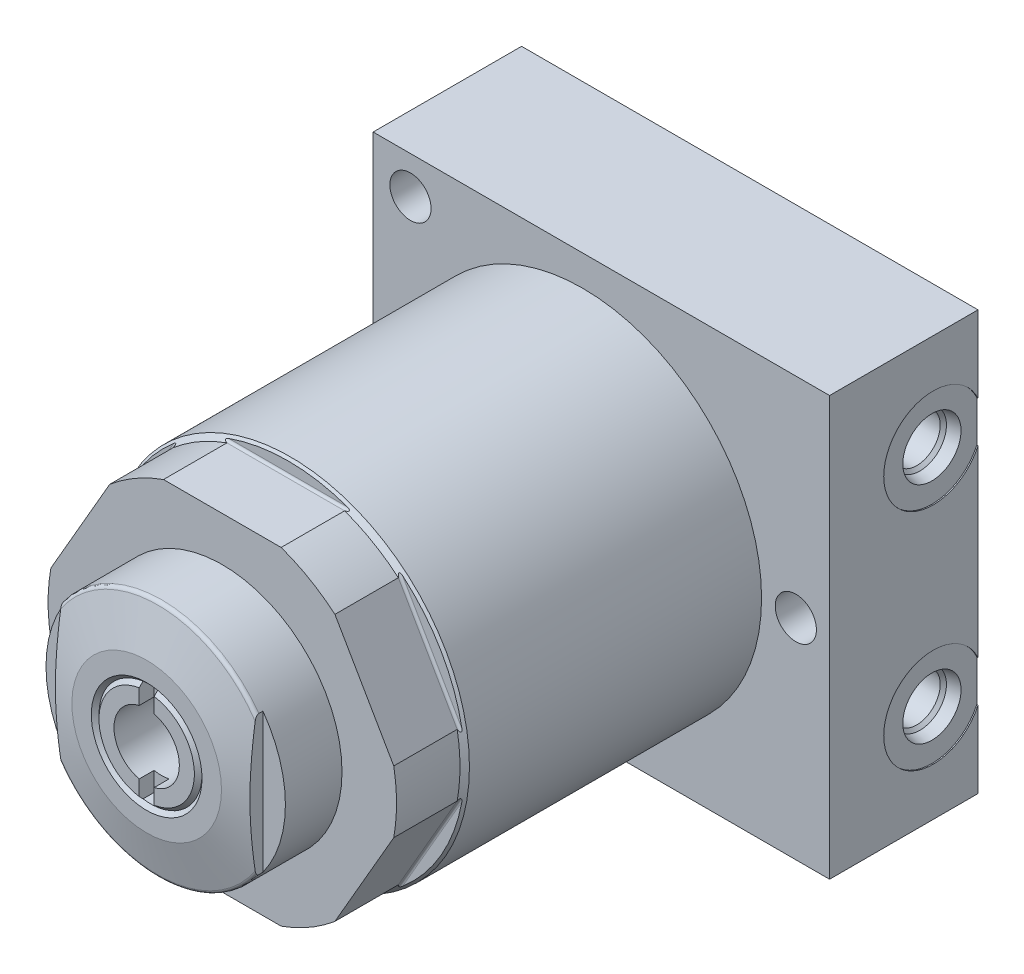
from build123d import *

# Parameters (mm, degrees)
SKETCH1_R           = 37.973
EXTRUDE1_DEPTH      = 96.8502
CUT_EXTRUDE1_DEPTH  = 45.5676
SKETCH13_W          = 16.0528
SKETCH13_H          = 25.4
S2D0011_W           = 6.9342
S2D0011_H           = 16.002
SKETCH16_W          = 96.8502
SKETCH16_H          = 31.496
EXTRUDE2_DEPTH      = 44.45
EXTRUDE2_DEPTH_BACK = 44.45
SKETCH17_R          = 10.4775
CUT_EXTRUDE9_DEPTH  = 0.254
SKETCH18_R          = 10.4775
CUT_EXTRUDE10_DEPTH = 0.254
HOLE1_D             = 8.7376
HOLE1_DEPTH         = 31.496
CIRPATTERN2_COUNT   = 6
CUT_EXTRUDE11_DEPTH = 4.0386
CUT_EXTRUDE12_DEPTH = 3.175


with BuildPart() as part:
    # Sketch1 → Extrude1 (new body)
    with BuildSketch(Plane.XY):
        Circle(SKETCH1_R)
    extrude(amount=EXTRUDE1_DEPTH)

    # Sketch2 → Cut-Extrude1 (cut, symmetric)
    with BuildSketch(Plane(origin=(0, 0, 0), x_dir=(0, 0, 1), z_dir=(1, 0, 0))):
        with BuildLine():
            Line((82.8802, 37.973), (82.8802, 35.306))
            ThreePointArc((82.8802, 35.306), (83.028989755, 34.946789755), (83.3882, 34.798))
            Line((83.3882, 34.798), (96.8502, 34.798))
            Line((96.8502, 34.798), (96.8502, 37.973))
            Line((96.8502, 37.973), (82.8802, 37.973))
        make_face()
    cut_extrude1 = extrude(amount=CUT_EXTRUDE1_DEPTH, both=True, mode=Mode.SUBTRACT)

    # Sketch10 → Cut-Revolve1 (revolve, cut)
    with BuildSketch(Plane(origin=(0, 0, 0), x_dir=(0, 0, -1), z_dir=(1, 0, 0)), mode=Mode.PRIVATE) as cut_revolve1_sk:
        Polygon((-96.8502, 36.9697), (-83.3882, 36.9697), (-82.3849, 37.973), (-96.8502, 37.973), align=None)
    revolve(cut_revolve1_sk.sketch.rotate(Axis((0, 0, 97.573465), (0, 0, -1)), 90), axis=Axis((0, 0, 97.573465), (0, 0, -1)), mode=Mode.SUBTRACT)  # turned: the seam where the file's is

    # Sketch13 → Revolve1 (revolve)
    with BuildSketch(Plane(origin=(0, 0, 0), x_dir=(0, 0, -1), z_dir=(1, 0, 0)), mode=Mode.PRIVATE) as revolve1_sk:
        with Locations((-104.8766, 12.7)):
            Rectangle(SKETCH13_W, SKETCH13_H)
    revolve(revolve1_sk.sketch.rotate(Axis((0, 0, 113.59896), (0, 0, -1)), 90), axis=Axis((0, 0, 113.59896), (0, 0, -1)))  # turned: the seam where the file's is

    # S2D0011 → Cut-Revolve4 (revolve, cut)
    with BuildSketch(Plane(origin=(-6.9342, 0, 112.8014), x_dir=(-1, 0, 0), z_dir=(0, 1, 0)), mode=Mode.PRIVATE) as cut_revolve4_sk:
        with Locations((-3.4671, -7.8994)):
            Rectangle(S2D0011_W, S2D0011_H)
    revolve(cut_revolve4_sk.sketch.rotate(Axis((0, 0, 71.846012298), (0, 0, 1)), 180), axis=Axis((0, 0, 71.846012298), (0, 0, 1)), mode=Mode.SUBTRACT)  # turned: the seam where the file's is

    # Sketch15 → Cut-Revolve5 (revolve, cut)
    with BuildSketch(Plane(origin=(0, 0, 0), x_dir=(0, 0, -1), z_dir=(1, 0, 0)), mode=Mode.PRIVATE) as cut_revolve5_sk:
        with BuildLine():
            Line((-112.903, 15.875), (-110.513124294, 24.797494276))
            ThreePointArc((-110.513124294, 24.797494276), (-110.222831614, 25.232014325), (-109.728, 25.4))
            Line((-109.728, 25.4), (-112.903, 25.4))
            Line((-112.903, 25.4), (-112.903, 15.875))
        make_face()
    revolve(cut_revolve5_sk.sketch.rotate(Axis((0, 0, 112.96015), (0, 0, -1)), 90), axis=Axis((0, 0, 112.96015), (0, 0, -1)), mode=Mode.SUBTRACT)  # turned: the seam where the file's is

    # Sketch16 → Extrude2 (add, two sides)
    with BuildSketch(Plane(origin=(0, 0, 0), x_dir=(-1, 0, 0), z_dir=(0, 1, 0))) as extrude2_sk:
        with Locations((-3.9751, 4.6482)):
            Rectangle(SKETCH16_W, SKETCH16_H)
    extrude(amount=EXTRUDE2_DEPTH)
    extrude(extrude2_sk.sketch, amount=-EXTRUDE2_DEPTH_BACK)

    # Sketch17 → Cut-Extrude9 (cut)
    with BuildSketch(Plane(origin=(52.4002, 0, 0), x_dir=(0, 0, -1), z_dir=(1, 0, 0))):
        with Locations((1.5748, -23.8252)):
            Circle(SKETCH17_R)
    extrude(amount=-CUT_EXTRUDE9_DEPTH, mode=Mode.SUBTRACT)

    # Sketch18 → Cut-Extrude10 (cut)
    with BuildSketch(Plane(origin=(52.4002, 0, 0), x_dir=(0, 0, -1), z_dir=(1, 0, 0))):
        with Locations((1.5748, 23.8252)):
            Circle(SKETCH18_R)
    extrude(amount=-CUT_EXTRUDE10_DEPTH, mode=Mode.SUBTRACT)

    # S2D0002 → Cut-Revolve6 (revolve, cut)
    with BuildSketch(Plane(origin=(52.1462, -23.8125, -1.5748), x_dir=(0, -1, 0), z_dir=(0, 0, 1)), mode=Mode.PRIVATE) as cut_revolve6_sk:
        Polygon((0.0127, 0), (6.1976, 0), (5.655006865, -2.5527), (4.9911, -3.216606865), (4.9911, -17.272), (0.0127, -17.272), align=None)
    revolve(cut_revolve6_sk.sketch.rotate(Axis((31.448179261, -23.8252, -1.5748), (1, 0, 0)), 270), axis=Axis((31.448179261, -23.8252, -1.5748), (1, 0, 0)), mode=Mode.SUBTRACT)  # turned: the seam where the file's is

    # S2D0001 → Cut-Revolve7 (revolve, cut)
    with BuildSketch(Plane(origin=(52.1462, 23.8125, -1.5748), x_dir=(0, -1, 0), z_dir=(0, 0, 1)), mode=Mode.PRIVATE) as cut_revolve7_sk:
        Polygon((-0.0127, 0), (6.1722, 0), (5.629606865, -2.5527), (4.9657, -3.216606865), (4.9657, -17.272), (-0.0127, -17.272), align=None)
    revolve(cut_revolve7_sk.sketch.rotate(Axis((31.323284066, 23.8252, -1.5748), (1, 0, 0)), 270), axis=Axis((31.323284066, 23.8252, -1.5748), (1, 0, 0)), mode=Mode.SUBTRACT)  # turned: the seam where the file's is

    # Hole1
    with Locations(Plane.XY.offset(20.3962)):
        with Locations((-36.5252, -36.5252), (45.2374, 0), (-36.5252, 36.5252)):
            Hole(HOLE1_D / 2, depth=HOLE1_DEPTH)

    # CirPattern2: Cut-Extrude1 ×6 about axis
    cirpattern2_axis = Axis((0, 0, 0), (0, 0, 1))
    for i in range(1, CIRPATTERN2_COUNT):
        add(cut_extrude1.rotate(cirpattern2_axis, i * 360 / CIRPATTERN2_COUNT), mode=Mode.SUBTRACT)

    # Sketch23 → Cut-Extrude11 (cut)
    with BuildSketch(Plane.XY.offset(112.903)):
        with BuildLine():
            Line((-20.6375, 14.807214247), (-20.6375, -14.807214247))
            ThreePointArc((-20.6375, -14.807214247), (-25.4, 0), (-20.6375, 14.807214247))
        make_face()
        with BuildLine():
            Line((20.6375, 14.807214247), (20.6375, -14.807214247))
            ThreePointArc((20.6375, -14.807214247), (25.4, 0), (20.6375, 14.807214247))
        make_face()
    extrude(amount=-CUT_EXTRUDE11_DEPTH, mode=Mode.SUBTRACT)

    # Sketch24 → Cut-Revolve8 (revolve, cut)
    with BuildSketch(Plane(origin=(0, 0, 0), x_dir=(1, 0, 0), z_dir=(0, 1, 0)), mode=Mode.PRIVATE) as cut_revolve8_sk:
        Polygon((-10.1219, -112.903), (-10.9347, -112.0902), (-11.7475, -112.903), align=None)
    revolve(cut_revolve8_sk.sketch.rotate(Axis((0, 0, -10.08126), (0, 0, -1)), 180), axis=Axis((0, 0, -10.08126), (0, 0, -1)), mode=Mode.SUBTRACT)  # turned: the seam where the file's is

    # Sketch25 → Cut-Extrude12 (cut)
    with BuildSketch(Plane.XY.offset(112.903)):
        with BuildLine():
            Line((-1.5875, 10.818849654), (-1.5875, -10.818849654))
            ThreePointArc((-1.5875, -10.818849654), (0, -10.9347), (1.5875, -10.818849654))
            Line((1.5875, -10.818849654), (1.5875, 10.818849654))
            ThreePointArc((1.5875, 10.818849654), (0, 10.9347), (-1.5875, 10.818849654))
        make_face()
    extrude(amount=-CUT_EXTRUDE12_DEPTH, mode=Mode.SUBTRACT)


solid = part.part
